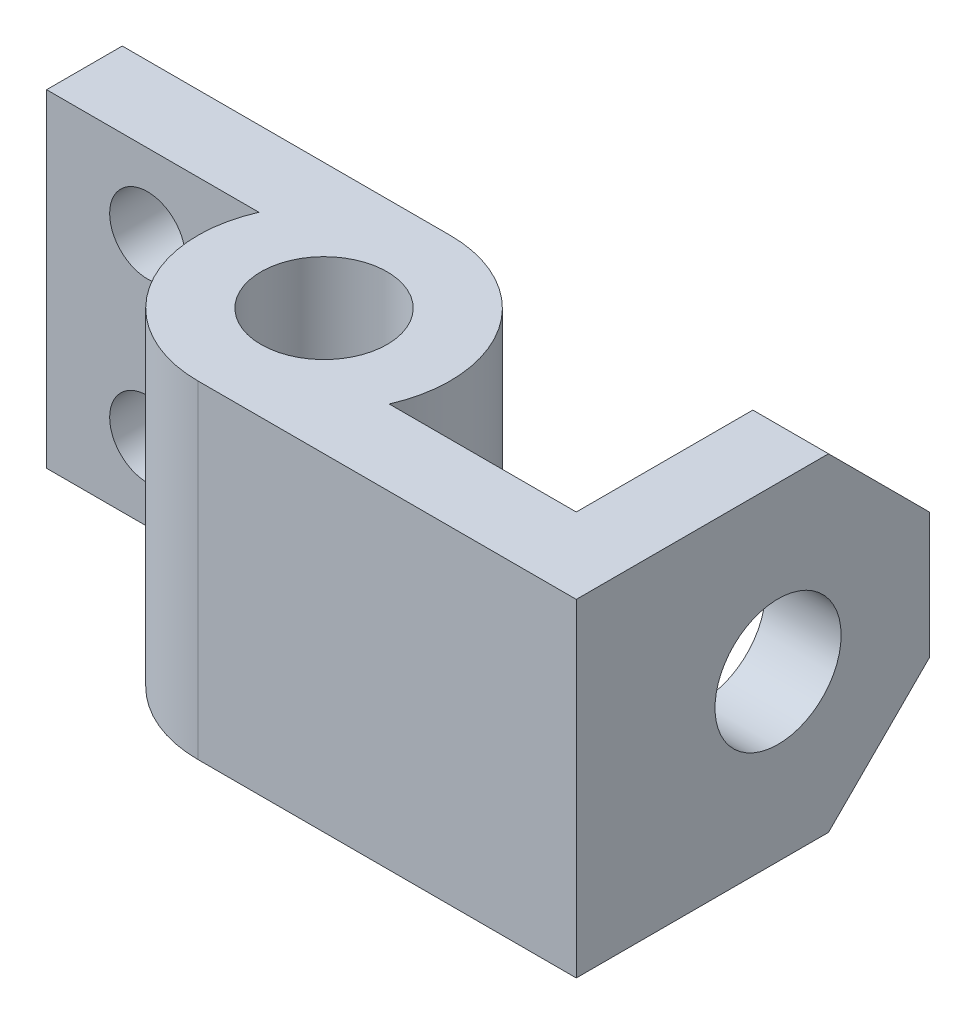
from build123d import *

# Parameters (mm, degrees)
SKETCH1_R           = 15.875
BOSS_EXTRUDE1_DEPTH = 82.55
SKETCH2_R           = 9.525
CUT_EXTRUDE1_DEPTH  = 64.5
CUT_EXTRUDE2_DEPTH  = 19.05
SKETCH5_R           = 15.875
CUT_EXTRUDE3_DEPTH  = 19.05


with BuildPart() as part:
    # Sketch1 → Boss-Extrude1 (new body)
    with BuildSketch(Plane(origin=(0, 0, 0), x_dir=(1, 0, 0), z_dir=(0, 1, 0))):
        with BuildLine():
            Line((0, 31.75), (-82.55, 31.75))
            Line((-82.55, 31.75), (-82.55, 12.7))
            Line((-82.55, 12.7), (-29.099355663, 12.7))
            ThreePointArc((-29.099355663, 12.7), (-26.563955842, -17.390191201), (0, -31.75))
            Line((0, -31.75), (95.25, -31.75))
            Line((95.25, -31.75), (95.25, 57.15))
            Line((95.25, 57.15), (76.2, 57.15))
            Line((76.2, 57.15), (76.2, -12.7))
            Line((76.2, -12.7), (29.099355663, -12.7))
            ThreePointArc((29.099355663, -12.7), (26.563955842, 17.390191201), (0, 31.75))
        make_face()
        Circle(SKETCH1_R, mode=Mode.SUBTRACT)
    extrude(amount=BOSS_EXTRUDE1_DEPTH)

    # Sketch2 → Cut-Extrude1 (cut, through all)
    with BuildSketch(Plane(origin=(0, 0, -31.75), x_dir=(-1, 0, 0), z_dir=(0, 0, -1))):
        with Locations((57.15, 63.5)):
            Circle(SKETCH2_R)
        with Locations((57.15, 19.05)):
            Circle(SKETCH2_R)
    extrude(amount=-CUT_EXTRUDE1_DEPTH, mode=Mode.SUBTRACT)

    # Sketch4 → Cut-Extrude2 (cut)
    with BuildSketch(Plane(origin=(95.25, 0, 0), x_dir=(0, 0, -1), z_dir=(1, 0, 0))):
        Polygon((31.75, 0), (57.15, 0), (57.15, 25.4), align=None)
        Polygon((31.75, 82.55), (57.15, 82.55), (57.15, 57.15), align=None)
    extrude(amount=-CUT_EXTRUDE2_DEPTH, mode=Mode.SUBTRACT)

    # Sketch5 → Cut-Extrude3 (cut)
    with BuildSketch(Plane(origin=(95.25, 0, 0), x_dir=(0, 0, -1), z_dir=(1, 0, 0))):
        with Locations((19.05, 41.402)):
            Circle(SKETCH5_R)
    extrude(amount=-CUT_EXTRUDE3_DEPTH, mode=Mode.SUBTRACT)


solid = part.part
